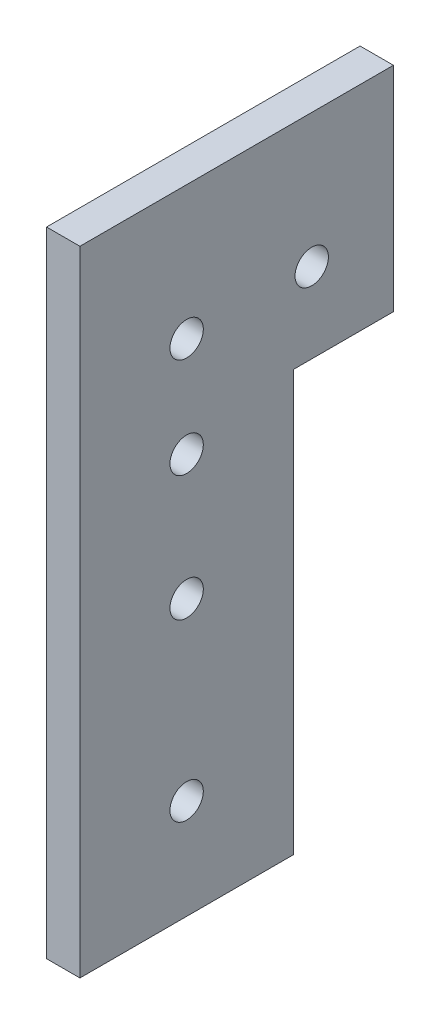
from build123d import *

# Parameters (mm, degrees)
BOSS_EXTRUDE1_DEPTH = 6.35
SKETCH3_R           = 3.175
CUT_EXTRUDE1_DEPTH  = 6.35


with BuildPart() as part:
    # Sketch1 → Boss-Extrude1 (new body)
    with BuildSketch(Plane(origin=(0, 0, 0), x_dir=(0, 0, -1), z_dir=(1, 0, 0))):
        Polygon((0, 0), (40.64, 0), (40.64, 80.01), (59.69, 80.01), (59.69, 120.65), (40.64, 120.65), (0, 120.65), align=None)
    extrude(amount=BOSS_EXTRUDE1_DEPTH)

    # Sketch3 → Cut-Extrude1 (cut)
    with BuildSketch(Plane(origin=(6.35, 0, 0), x_dir=(0, 0, -1), z_dir=(1, 0, 0))):
        with Locations((20.32, 19.05)):
            Circle(SKETCH3_R)
        with Locations((20.32, 52.3875)):
            Circle(SKETCH3_R)
        with Locations((20.32, 76.2)):
            Circle(SKETCH3_R)
        with Locations((20.32, 95.25)):
            Circle(SKETCH3_R)
        with Locations((44.1325, 95.25)):
            Circle(SKETCH3_R)
    extrude(amount=-CUT_EXTRUDE1_DEPTH, mode=Mode.SUBTRACT)


solid = part.part
